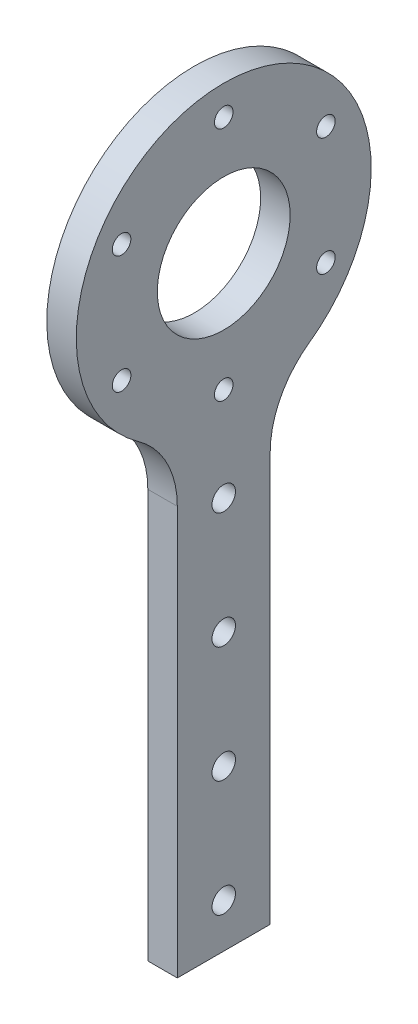
from build123d import *

# Parameters (mm, degrees)
BOSS_EXTRUDE1_DEPTH = 6.35
FILLET1_R           = 20
SKETCH2_R           = 14.3
SKETCH2_R_2         = 2
CUT_EXTRUDE1_DEPTH  = 7.35
SKETCH3_R           = 2.525
CUT_EXTRUDE2_DEPTH  = 7.35


with BuildPart() as part:
    # Sketch1 → Boss-Extrude1 (new body)
    with BuildSketch(Plane(origin=(0, 0, 0), x_dir=(0, 0, -1), z_dir=(1, 0, 0))):
        with BuildLine():
            Line((-10, -30.134075396), (-10, -130.134075396))
            Line((-10, -130.134075396), (10, -130.134075396))
            Line((10, -130.134075396), (10, -30.134075396))
            ThreePointArc((10, -30.134075396), (0, 31.75), (-10, -30.134075396))
        make_face()
    extrude(amount=BOSS_EXTRUDE1_DEPTH)

    # Fillet1
    fillet1_edges = [part.edges().sort_by_distance(p)[0] for p in [
        (3.175, -30.134075396, -10),
        (3.175, -30.134075396, 10),
    ]]
    fillet(fillet1_edges, radius=FILLET1_R)

    # Sketch2 → Cut-Extrude1 (cut, through all)
    with BuildSketch(Plane(origin=(6.35, 0, 0), x_dir=(0, 0, -1), z_dir=(1, 0, 0))):
        Circle(SKETCH2_R)
        with Locations((0, 25.4)):
            Circle(SKETCH2_R_2)
        with Locations((21.997045256, 12.7)):
            Circle(SKETCH2_R_2)
        with Locations((21.997045256, -12.7)):
            Circle(SKETCH2_R_2)
        with Locations((0, -25.4)):
            Circle(SKETCH2_R_2)
        with Locations((-21.997045256, -12.7)):
            Circle(SKETCH2_R_2)
        with Locations((-21.997045256, 12.7)):
            Circle(SKETCH2_R_2)
    extrude(amount=-CUT_EXTRUDE1_DEPTH, mode=Mode.SUBTRACT)

    # Sketch3 → Cut-Extrude2 (cut, through all)
    with BuildSketch(Plane(origin=(6.35, 0, 0), x_dir=(0, 0, -1), z_dir=(1, 0, 0))):
        with Locations((0, -120.63662428)):
            Circle(SKETCH3_R)
        with Locations((0, -95.63662428)):
            Circle(SKETCH3_R)
        with Locations((0, -70.63662428)):
            Circle(SKETCH3_R)
        with Locations((0, -45.63662428)):
            Circle(SKETCH3_R)
    extrude(amount=-CUT_EXTRUDE2_DEPTH, mode=Mode.SUBTRACT)


solid = part.part
